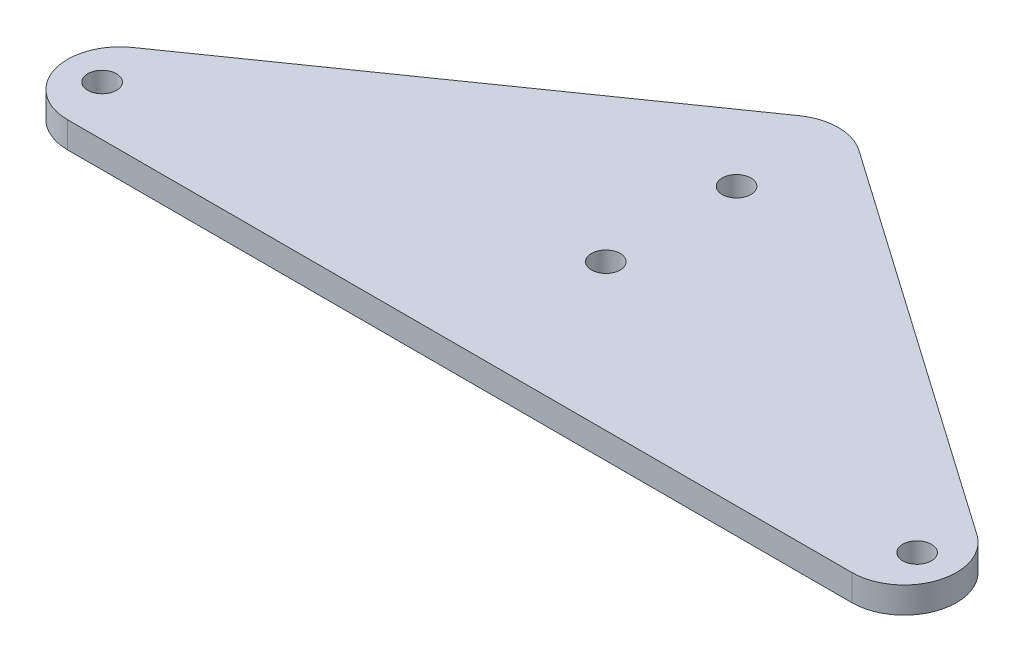
from build123d import *

# Parameters (mm, degrees)
BOSS_EXTRUDE1_DEPTH  = 5
M5_CLEARANCE_HOLE1_D = 5.5
M5_CLEARANCE_HOLE2_D = 5.5


with BuildPart() as part:
    # Sketch2 → Boss-Extrude1 (new body)
    with BuildSketch(Plane(origin=(0, 0, 0), x_dir=(1, 0, 0), z_dir=(0, 1, 0))):
        with BuildLine():
            Line((-5.72861373, 62.663882494), (-80.72861373, 10.24579688))
            ThreePointArc((-80.72861373, 10.24579688), (-84.538480676, -0.953622176), (-75, -7.950725842))
            Line((-75, -7.950725842), (75, -7.950725842))
            ThreePointArc((75, -7.950725842), (84.538480676, -0.953622176), (80.72861373, 10.24579688))
            Line((80.72861373, 10.24579688), (5.72861373, 62.663882494))
            ThreePointArc((5.72861373, 62.663882494), (0, 64.467359772), (-5.72861373, 62.663882494))
        make_face()
    extrude(amount=BOSS_EXTRUDE1_DEPTH)

    # M5 Clearance Hole1 (through all)
    with Locations(Plane(origin=(0, 5, 0), x_dir=(1, 0, 0), z_dir=(0, 1, 0))):
        with Locations((0, 45), (0, 20)):
            Hole(M5_CLEARANCE_HOLE1_D / 2)

    # M5 Clearance Hole2 (through all)
    with Locations(Plane(origin=(0, 5, 0), x_dir=(1, 0, 0), z_dir=(0, 1, 0))):
        with Locations((-77.928915997, 1.587505431)):
            m5_clearance_hole2 = Hole(M5_CLEARANCE_HOLE2_D / 2)

    # Mirror1: M5 Clearance Hole2 across plane
    add(m5_clearance_hole2.mirror(Plane(origin=(0, 0, 0), x_dir=(0, 0, 1), z_dir=(1, 0, 0))), mode=Mode.SUBTRACT)


solid = part.part
